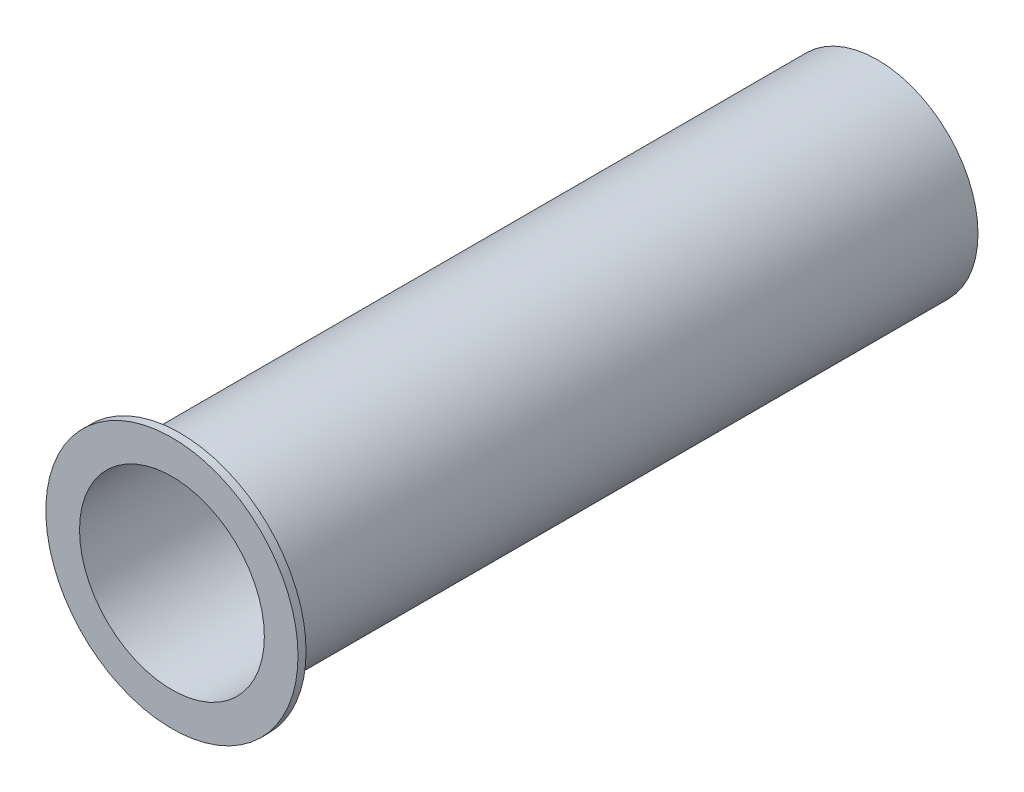
from build123d import *

# Parameters (mm, degrees)
ESQUISSE1_R        = 6.25
ESQUISSE1_R_2      = 5.75
BOSS_EXTRU_1_DEPTH = 43.4
ESQUISSE2_R        = 7.845
ESQUISSE2_R_2      = 5.75
BOSS_EXTRU_2_DEPTH = 0.5


with BuildPart() as part:
    # Esquisse1 → Boss.-Extru.1 (new body)
    with BuildSketch(Plane.XY):
        Circle(ESQUISSE1_R)
        Circle(ESQUISSE1_R_2, mode=Mode.SUBTRACT)
    extrude(amount=BOSS_EXTRU_1_DEPTH)

    # Esquisse2 → Boss.-Extru.2 (add)
    with BuildSketch(Plane.XY.offset(43.4)):
        Circle(ESQUISSE2_R)
        Circle(ESQUISSE2_R_2, mode=Mode.SUBTRACT)
    extrude(amount=BOSS_EXTRU_2_DEPTH)


solid = part.part
